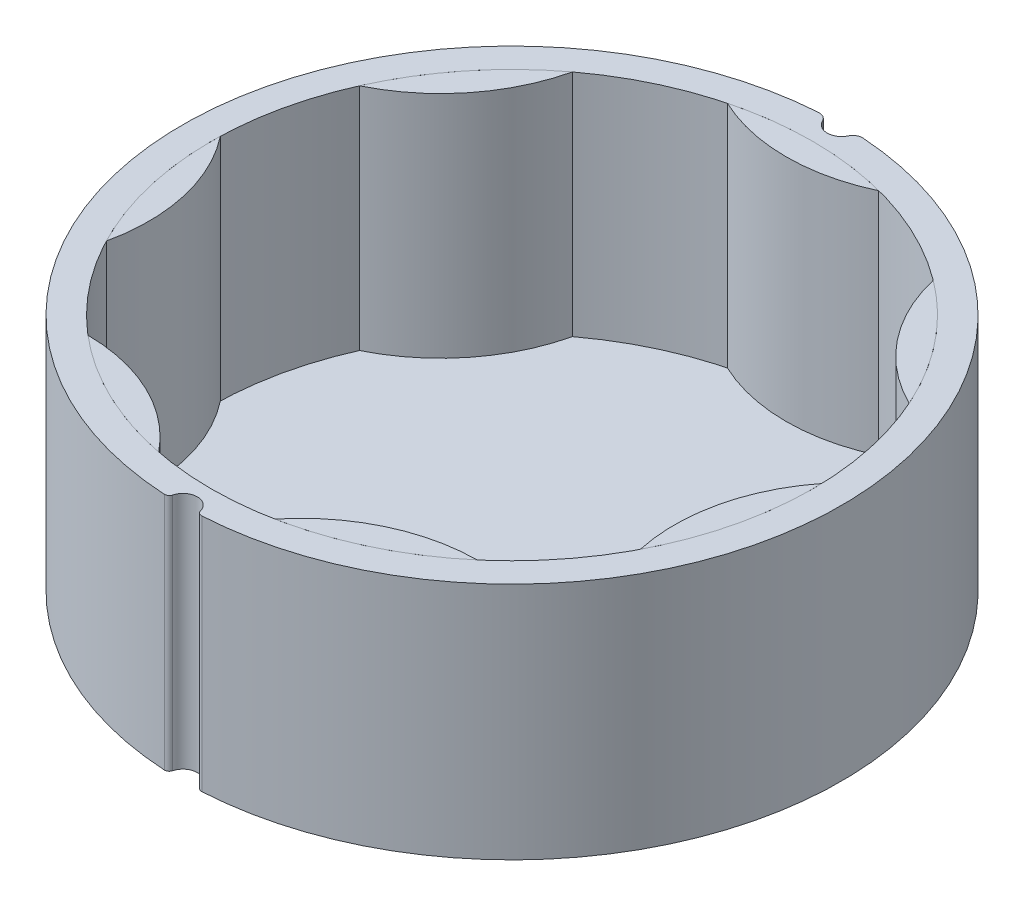
from build123d import *

# Parameters (mm, degrees)
BOSS_EXTRUDE1_DEPTH = 25
CUT_EXTRUDE2_REACH  = 28
CUT_EXTRUDE2_START  = 1
BOSS_EXTRUDE2_DEPTH = 25
CIRPATTERN2_COUNT   = 7


with BuildPart() as part:
    # Sketch1 → Boss-Extrude1 (new body)
    with BuildSketch(Plane(origin=(0, 0, 0), x_dir=(1, 0, 0), z_dir=(0, 1, 0))):
        with BuildLine():
            ThreePointArc((1.451818925, -34.068556857), (1.641248992, -34.346908706), (1.964225605, -34.442038138))
            ThreePointArc((1.964225605, -34.442038138), (34.499528846, -0.178302888), (2.324135821, 34.423627607))
            ThreePointArc((2.324135821, 34.423627607), (1.751838249, 34.289058819), (1.354061739, 33.856153382))
            ThreePointArc((1.354061739, 33.856153382), (0, 33.001534515), (-1.354061739, 33.856153382))
            ThreePointArc((-1.354061739, 33.856153382), (-1.751838249, 34.289058819), (-2.324135821, 34.423627607))
            ThreePointArc((-2.324135821, 34.423627607), (-34.499528846, -0.178302888), (-1.964225605, -34.442038138))
            ThreePointArc((-1.964225605, -34.442038138), (-1.641248992, -34.346908706), (-1.451818925, -34.068556857))
            ThreePointArc((-1.451818925, -34.068556857), (0, -32.945679925), (1.451818925, -34.068556857))
        make_face()
    extrude(amount=BOSS_EXTRUDE1_DEPTH)

    # Sketch2 → Cut-Extrude2 (cut, up to next)
    with BuildSketch(Plane(origin=(0, 0, 0), x_dir=(1, 0, 0), z_dir=(0, 1, 0)).offset(CUT_EXTRUDE2_START), mode=Mode.PRIVATE) as cut_extrude2_sk1:
        with BuildLine():
            ThreePointArc((-7.935237994, 30.484126984), (-19.265123971, -24.92197822), (31.5, 0))
            ThreePointArc((31.5, 0), (24.92197822, 19.265123971), (7.935237994, 30.484126984))
            ThreePointArc((7.935237994, 30.484126984), (0, 28.7), (-7.935237994, 30.484126984))
        make_face()
    cut_extrude2_tool1 = extrude(cut_extrude2_sk1.sketch, amount=CUT_EXTRUDE2_REACH, mode=Mode.PRIVATE) & part.part
    add(cut_extrude2_tool1.solids().sort_by_distance((0, 1, 0.291722))[0], mode=Mode.SUBTRACT)
    # Sketch2 → Cut-Extrude2 (cut, up to next)
    with BuildSketch(Plane(origin=(0, 0, 0), x_dir=(1, 0, 0), z_dir=(0, 1, 0)).offset(CUT_EXTRUDE2_START), mode=Mode.PRIVATE) as cut_extrude2_sk2:
        with BuildLine():
            ThreePointArc((-7.935237994, 30.484126984), (0, 28.7), (7.935237994, 30.484126984))
            ThreePointArc((7.935237994, 30.484126984), (0, 31.5), (-7.935237994, 30.484126984))
        make_face()
    cut_extrude2_tool2 = extrude(cut_extrude2_sk2.sketch, amount=CUT_EXTRUDE2_REACH, mode=Mode.PRIVATE) & part.part
    add(cut_extrude2_tool2.solids().sort_by_distance((0, 1, -30.173357))[0], mode=Mode.SUBTRACT)


with BuildPart() as body_2:
    # Sketch2_2 → Boss-Extrude2 (new body)
    with BuildSketch(Plane(origin=(0, 0, 0), x_dir=(1, 0, 0), z_dir=(0, 1, 0))):
        with BuildLine():
            ThreePointArc((-7.935237994, 30.484126984), (0, 28.7), (7.935237994, 30.484126984))
            ThreePointArc((7.935237994, 30.484126984), (0, 31.5), (-7.935237994, 30.484126984))
        make_face()
    extrude(amount=BOSS_EXTRUDE2_DEPTH)


with BuildPart() as cirpattern2_1:
    # CirPattern2: pattern copy
    add(body_2.part.rotate(Axis((0, 0, 0), (0, 1, 0)), 1 * 360 / CIRPATTERN2_COUNT))


with BuildPart() as cirpattern2_2:
    # CirPattern2: pattern copy
    add(body_2.part.rotate(Axis((0, 0, 0), (0, 1, 0)), 2 * 360 / CIRPATTERN2_COUNT))


with BuildPart() as cirpattern2_3:
    # CirPattern2: pattern copy
    add(body_2.part.rotate(Axis((0, 0, 0), (0, 1, 0)), 3 * 360 / CIRPATTERN2_COUNT))


with BuildPart() as cirpattern2_4:
    # CirPattern2: pattern copy
    add(body_2.part.rotate(Axis((0, 0, 0), (0, 1, 0)), 4 * 360 / CIRPATTERN2_COUNT))


with BuildPart() as cirpattern2_5:
    # CirPattern2: pattern copy
    add(body_2.part.rotate(Axis((0, 0, 0), (0, 1, 0)), 5 * 360 / CIRPATTERN2_COUNT))


with BuildPart() as cirpattern2_6:
    # CirPattern2: pattern copy
    add(body_2.part.rotate(Axis((0, 0, 0), (0, 1, 0)), 6 * 360 / CIRPATTERN2_COUNT))


solid = Compound([part.part, body_2.part, cirpattern2_1.part, cirpattern2_2.part, cirpattern2_3.part, cirpattern2_4.part, cirpattern2_5.part, cirpattern2_6.part])
